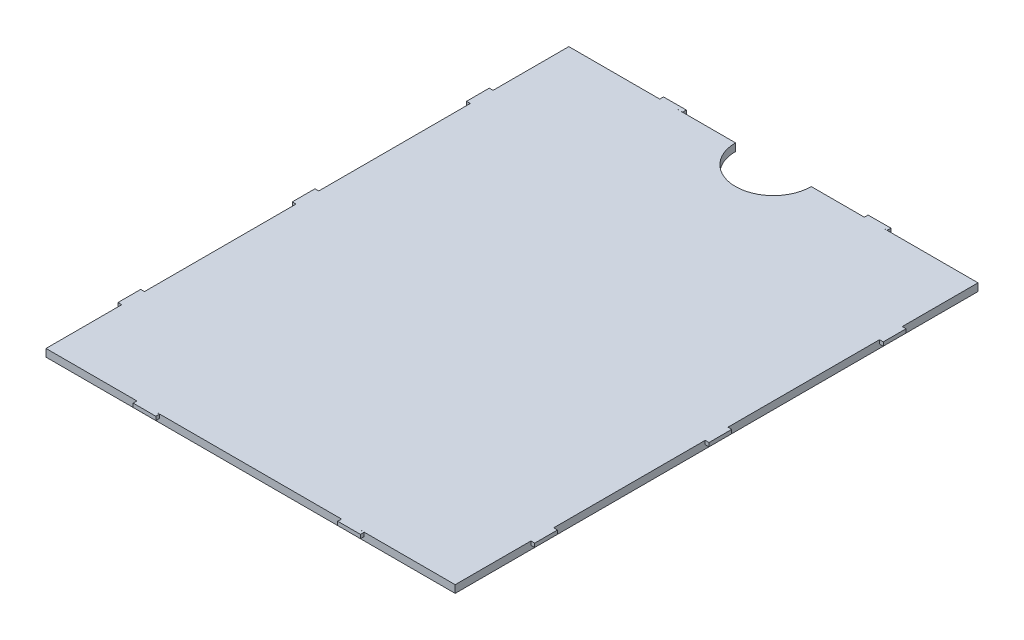
from build123d import *

# Parameters (mm, degrees)
SKETCH1_W           = 54
SKETCH1_H           = 69
BOSS_EXTRUDE1_DEPTH = 1
BOSS_EXTRUDE2_START = -0.5
SKETCH3_W           = 0.5
SKETCH3_H           = 3
BOSS_EXTRUDE2_DEPTH = 0.5
SKETCH4_R           = 5
CUT_EXTRUDE1_DEPTH  = 1


with BuildPart() as part:
    # Sketch1 → Boss-Extrude1 (new body)
    with BuildSketch(Plane.XZ.offset(-34.2740501)):
        with Locations((-40.101257217, 62.307503177)):
            Rectangle(SKETCH1_W, SKETCH1_H)
    extrude(amount=-BOSS_EXTRUDE1_DEPTH)

    # Sketch3 → Boss-Extrude2 (add)
    with BuildSketch(Plane.XZ.offset(-34.2740501).offset(BOSS_EXTRUDE2_START)):
        with Locations((-67.351257217, 85.307503177)):
            Rectangle(SKETCH3_W, SKETCH3_H)
        with Locations((-12.851257217, 85.307503177)):
            Rectangle(SKETCH3_W, SKETCH3_H)
        with Locations((-12.851257217, 62.307503177)):
            Rectangle(SKETCH3_W, SKETCH3_H)
        Polygon((-13.101257217, 39.307503177), (-13.101257217, 37.807503177), (-12.601257217, 37.807503177), (-12.601257217, 40.807503177), (-13.101257217, 40.807503177), align=None)
        Polygon((-25.101261235, 27.80403111), (-26.601257217, 27.807503177), (-28.101261235, 27.807503177), (-28.102410554, 27.310976583), (-25.102418591, 27.304032449), align=None)
        Polygon((-52.101261235, 27.80403111), (-53.601257217, 27.807503177), (-55.101261235, 27.807503177), (-55.102410554, 27.310976583), (-52.102418591, 27.304032449), align=None)
        with Locations((-67.351257217, 39.307503177)):
            Rectangle(SKETCH3_W, SKETCH3_H)
        with Locations((-67.351257217, 62.307503177)):
            Rectangle(SKETCH3_W, SKETCH3_H)
        Polygon((-55.102410554, 97.30402977), (-52.102418591, 97.310973905), (-52.101261235, 96.810975244), (-55.101253198, 96.80403111), align=None)
        Polygon((-28.102410554, 97.30402977), (-25.102418591, 97.310973905), (-25.101261235, 96.810975244), (-28.101253198, 96.80403111), align=None)
    extrude(amount=-BOSS_EXTRUDE2_DEPTH)

    # Sketch4 → Cut-Extrude1 (cut)
    with BuildSketch(Plane.XZ.offset(-34.2740501)):
        with Locations((-40.101257217, 27.807503177)):
            Circle(SKETCH4_R)
    extrude(amount=-CUT_EXTRUDE1_DEPTH, mode=Mode.SUBTRACT)


solid = part.part
